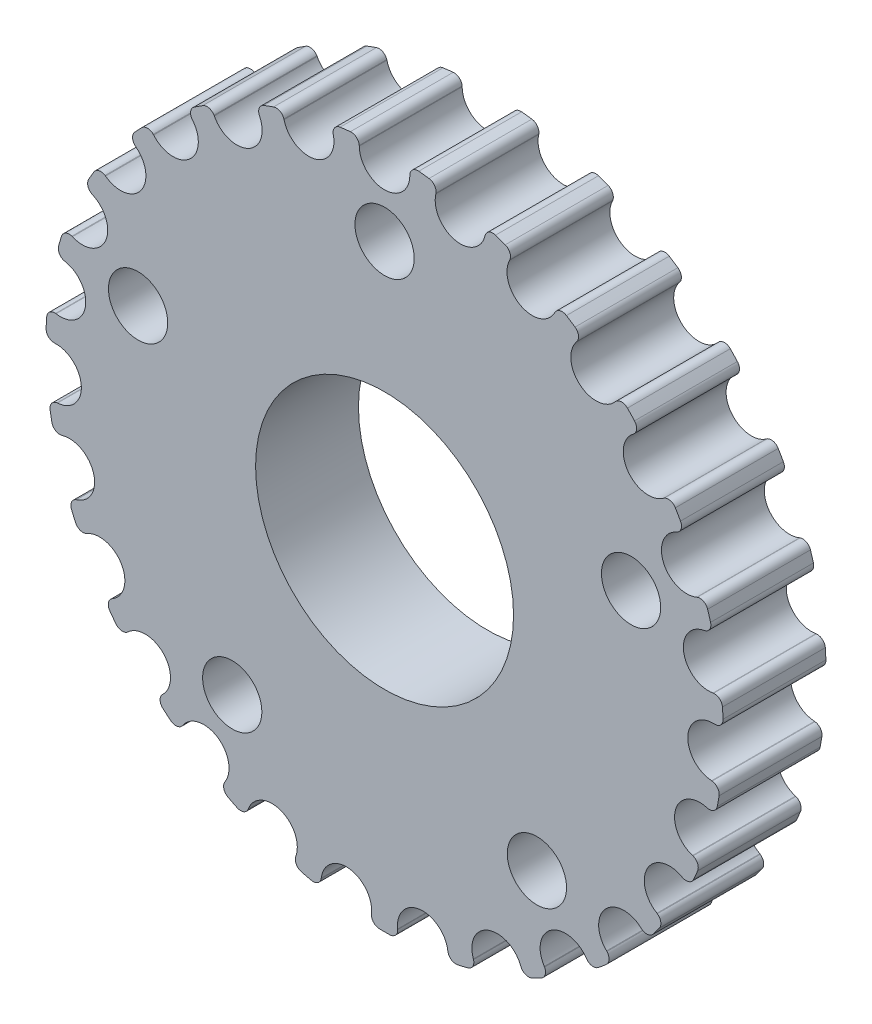
from build123d import *

# Parameters (mm, degrees)
SKETCH2_R                = 20.914417317
BOSS_EXTRUDE1_DEPTH      = 6.35
CUT_EXTRUDE1_DEPTH       = 31.251416553
FILLET1_R                = 0.5
CIRPATTERN1_COUNT        = 27
FILLET1_OF_CIRPATTERN1_R = 0.5
SKETCH4_R                = 7.9629
CUT_EXTRUDE2_DEPTH       = 31.238398104
F_6_CLEARANCE_HOLE1_D    = 3.6576
CIRPATTERN2_COUNT        = 5


with BuildPart() as part:
    # Sketch2 → Boss-Extrude1 (new body)
    with BuildSketch(Plane.XY):
        Circle(SKETCH2_R)
    extrude(amount=BOSS_EXTRUDE1_DEPTH)

    # Sketch3 → Cut-Extrude1 (cut, through all)
    with BuildSketch(Plane(origin=(0, 0, 0), x_dir=(-1, 0, 0), z_dir=(0, 0, -1))):
        with BuildLine():
            Line((-1.601360878, 20.853021246), (-1.56, 20.314417317))
            ThreePointArc((-1.56, 20.314417317), (0, 18.754417317), (1.56, 20.314417317))
            Line((1.56, 20.314417317), (1.601360878, 20.853021246))
            ThreePointArc((1.601360878, 20.853021246), (0, 20.914417317), (-1.601360878, 20.853021246))
        make_face()
    cut_extrude1 = extrude(amount=-CUT_EXTRUDE1_DEPTH, mode=Mode.SUBTRACT)

    # Fillet1
    fillet1_edges = [part.edges().sort_by_distance(p)[0] for p in [
        (-1.601360878, 20.853021246, 3.175),
        (1.601360878, 20.853021246, 3.175),
    ]]
    fillet(fillet1_edges, radius=FILLET1_R)

    # CirPattern1: Cut-Extrude1 ×27 about axis
    cirpattern1_axis = Axis((0, 0, 0), (0, 0, 1))
    for i in range(1, CIRPATTERN1_COUNT):
        add(cut_extrude1.rotate(cirpattern1_axis, i * 360 / CIRPATTERN1_COUNT), mode=Mode.SUBTRACT)

    # Fillet1 of CirPattern1
    fillet1_of_cirpattern1_edges = [part.edges().sort_by_distance(p)[0] for p in [
        (-6.36723364, 19.921626126, 3.175),
        (-3.250841664, 20.660224592, 3.175),
        (-10.789847189, 17.916250985, 3.175),
        (-7.927790491, 19.353629883, 3.175),
        (-14.630777283, 14.945006117, 3.175),
        (-12.177350079, 17.003675978, 3.175),
        (-17.682958387, 11.1680721, 3.175),
        (-15.770425574, 13.7370495, 3.175),
        (-19.781846626, 6.789064425, 3.175),
        (-18.513313343, 9.729855127, 3.175),
        (-20.814290395, 2.044056531, 3.175),
        (-20.258143598, 5.198121746, 3.175),
        (-20.72463038, -2.811146981, 3.175),
        (-20.910852088, 0.386156276, 3.175),
        (-19.517700177, -7.514800831, 3.175),
        (-20.43625113, -4.446626979, 3.175),
        (-17.258565705, -11.813329823, 3.175),
        (-18.859926583, -9.039691422, 3.175),
        (-14.06901749, -15.474999147, 3.175),
        (-16.266858513, -13.145423761, 3.175),
        (-10.121004899, -18.302407261, 3.175),
        (-12.796839889, -16.542482902, 3.175),
        (-5.627366315, -20.143127862, 3.175),
        (-8.636940315, -19.047732509, 3.175),
        (-0.830354957, -20.897927227, 3.175),
        (-4.011421053, -20.526113925, 3.175),
        (4.011421053, -20.526113925, 3.175),
        (0.830354957, -20.897927227, 3.175),
        (8.636940315, -19.047732509, 3.175),
        (5.627366315, -20.143127862, 3.175),
        (12.796839889, -16.542482902, 3.175),
        (10.121004899, -18.302407261, 3.175),
        (16.266858513, -13.145423761, 3.175),
        (14.06901749, -15.474999147, 3.175),
        (18.859926583, -9.039691422, 3.175),
        (17.258565705, -11.813329823, 3.175),
        (20.43625113, -4.446626979, 3.175),
        (19.517700177, -7.514800831, 3.175),
        (20.910852088, 0.386156276, 3.175),
        (20.72463038, -2.811146981, 3.175),
        (20.258143598, 5.198121746, 3.175),
        (20.814290395, 2.044056531, 3.175),
        (18.513313343, 9.729855127, 3.175),
        (19.781846626, 6.789064425, 3.175),
        (15.770425574, 13.7370495, 3.175),
        (17.682958387, 11.1680721, 3.175),
        (12.177350079, 17.003675978, 3.175),
        (14.630777283, 14.945006117, 3.175),
        (7.927790491, 19.353629883, 3.175),
        (10.789847189, 17.916250985, 3.175),
        (3.250841664, 20.660224592, 3.175),
        (6.36723364, 19.921626126, 3.175),
    ]]
    fillet(fillet1_of_cirpattern1_edges, radius=FILLET1_OF_CIRPATTERN1_R)

    # Sketch4 → Cut-Extrude2 (cut, through all)
    with BuildSketch(Plane.XY.offset(6.35)):
        Circle(SKETCH4_R)
    extrude(amount=-CUT_EXTRUDE2_DEPTH, mode=Mode.SUBTRACT)

    # 6 Clearance Hole1 (through all)
    with Locations(Plane.XY.offset(6.35)):
        with Locations((0, 16)):
            f_6_clearance_hole1 = Hole(F_6_CLEARANCE_HOLE1_D / 2)

    # CirPattern2: 6 Clearance Hole1 ×5 about axis
    cirpattern2_axis = Axis((0, 0, 6.35), (0, 0, 1))
    for i in range(1, CIRPATTERN2_COUNT):
        add(f_6_clearance_hole1.rotate(cirpattern2_axis, i * 360 / CIRPATTERN2_COUNT), mode=Mode.SUBTRACT)


solid = part.part
